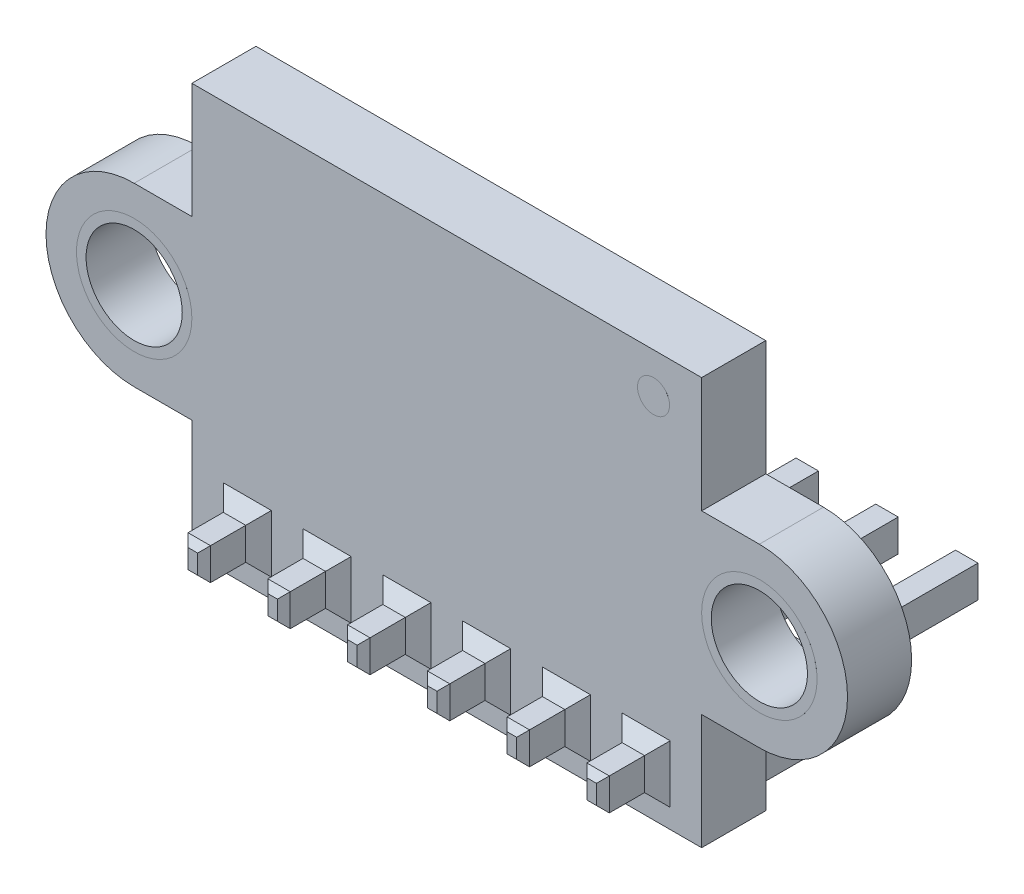
from build123d import *

# Parameters (mm, degrees)
SKETCH1_W                = 15.9
SKETCH1_H                = 12.7
BOSS_EXTRUDE1_DEPTH      = 1
SKETCH2_R                = 1.5
BOSS_EXTRUDE2_DEPTH      = 1
SKETCH3_W                = 15.6
SKETCH3_H                = 2.7
BOSS_EXTRUDE3_DEPTH      = 2.3
CHAMFER1_SIZE            = 0.5
SKETCH4_W                = 0.7
SKETCH4_H                = 1
BOSS_EXTRUDE4_DEPTH      = 5.9
BOSS_EXTRUDE4_DEPTH_BACK = 6
CHAMFER2_SIZE            = 0.2
CHAMFER3_SIZE            = 0.4
SKETCH5_R                = 1.8
SKETCH5_R_2              = 1.5
SKETCH5_R_3              = 0.5
BOSS_EXTRUDE5_DEPTH      = 0.0001


with BuildPart() as part:
    # Sketch1 → Boss-Extrude1 (new body, symmetric)
    with BuildSketch(Plane.XY):
        Rectangle(SKETCH1_W, SKETCH1_H)
    extrude(amount=BOSS_EXTRUDE1_DEPTH, both=True)

    # Sketch2 → Boss-Extrude2 (add, symmetric)
    with BuildSketch(Plane.XY):
        with BuildLine():
            Line((-9.75, 2.75), (-7.95, 2.75))
            Line((-7.95, 2.75), (-7.95, -2.75))
            Line((-7.95, -2.75), (-9.75, -2.75))
            ThreePointArc((-9.75, -2.75), (-12.5, 0), (-9.75, 2.75))
        make_face()
        with Locations((-9.75, 0)):
            Circle(SKETCH2_R, mode=Mode.SUBTRACT)
        with BuildLine():
            Line((9.75, -2.75), (7.95, -2.75))
            Line((7.95, -2.75), (7.95, 2.75))
            Line((7.95, 2.75), (9.75, 2.75))
            ThreePointArc((9.75, 2.75), (12.5, 0), (9.75, -2.75))
        make_face()
        with Locations((9.75, 0)):
            Circle(SKETCH2_R, mode=Mode.SUBTRACT)
    extrude(amount=BOSS_EXTRUDE2_DEPTH, both=True)

    # Sketch3 → Boss-Extrude3 (add)
    with BuildSketch(Plane(origin=(0, 0, -1), x_dir=(-1, 0, 0), z_dir=(0, 0, -1))):
        with Locations((0, -4.85)):
            Rectangle(SKETCH3_W, SKETCH3_H)
    extrude(amount=BOSS_EXTRUDE3_DEPTH)

    # Chamfer1
    chamfer1_edges = [part.edges().sort_by_distance(p)[0] for p in [
        (7.8, -3.5, -2.15),
        (7.8, -6.2, -2.15),
        (-7.8, -6.2, -2.15),
        (-7.8, -3.5, -2.15),
    ]]
    chamfer(chamfer1_edges, length=CHAMFER1_SIZE)

    # Sketch4 → Boss-Extrude4 (add, two sides)
    with BuildSketch(Plane(origin=(0, 0, -3.3), x_dir=(-1, 0, 0), z_dir=(0, 0, -1))) as boss_extrude4_sk:
        with Locations((-3.732, -4.85)):
            Rectangle(SKETCH4_W, SKETCH4_H)
        with Locations((-6.22, -4.85)):
            Rectangle(SKETCH4_W, SKETCH4_H)
        with Locations((-1.244, -4.85)):
            Rectangle(SKETCH4_W, SKETCH4_H)
        with Locations((1.244, -4.85)):
            Rectangle(SKETCH4_W, SKETCH4_H)
        with Locations((3.732, -4.85)):
            Rectangle(SKETCH4_W, SKETCH4_H)
        with Locations((6.22, -4.85)):
            Rectangle(SKETCH4_W, SKETCH4_H)
    extrude(amount=BOSS_EXTRUDE4_DEPTH)
    extrude(boss_extrude4_sk.sketch, amount=-BOSS_EXTRUDE4_DEPTH_BACK)

    # Chamfer2
    chamfer2_edges = [part.edges().sort_by_distance(p)[0] for p in [
        (4.082, -4.85, 2.7),
        (3.732, -4.35, 2.7),
        (3.382, -4.85, 2.7),
        (3.732, -5.35, 2.7),
        (4.082, -4.85, -9.2),
        (3.732, -5.35, -9.2),
        (3.382, -4.85, -9.2),
        (3.732, -4.35, -9.2),
        (1.594, -4.85, 2.7),
        (1.244, -4.35, 2.7),
        (0.894, -4.85, 2.7),
        (1.244, -5.35, 2.7),
        (1.594, -4.85, -9.2),
        (1.244, -5.35, -9.2),
        (0.894, -4.85, -9.2),
        (1.244, -4.35, -9.2),
        (-0.894, -4.85, 2.7),
        (-1.244, -4.35, 2.7),
        (-1.594, -4.85, 2.7),
        (-1.244, -5.35, 2.7),
        (-0.894, -4.85, -9.2),
        (-1.244, -5.35, -9.2),
        (-1.594, -4.85, -9.2),
        (-1.244, -4.35, -9.2),
        (-3.382, -4.85, 2.7),
        (-3.732, -4.35, 2.7),
        (-4.082, -4.85, 2.7),
        (-3.732, -5.35, 2.7),
        (-3.382, -4.85, -9.2),
        (-3.732, -5.35, -9.2),
        (-4.082, -4.85, -9.2),
        (-3.732, -4.35, -9.2),
        (-5.87, -4.85, 2.7),
        (-6.22, -4.35, 2.7),
        (-6.57, -4.85, 2.7),
        (-6.22, -5.35, 2.7),
        (-5.87, -4.85, -9.2),
        (-6.22, -5.35, -9.2),
        (-6.57, -4.85, -9.2),
        (-6.22, -4.35, -9.2),
        (6.57, -4.85, 2.7),
        (6.22, -4.35, 2.7),
        (5.87, -4.85, 2.7),
        (6.22, -5.35, 2.7),
        (6.57, -4.85, -9.2),
        (6.22, -5.35, -9.2),
        (5.87, -4.85, -9.2),
        (6.22, -4.35, -9.2),
    ]]
    chamfer(chamfer2_edges, length=CHAMFER2_SIZE)

    # Chamfer3
    chamfer3_edges = [part.edges().sort_by_distance(p)[0] for p in [
        (4.082, -4.85, 1),
        (3.732, -4.35, 1),
        (3.382, -4.85, 1),
        (3.732, -5.35, 1),
        (1.594, -4.85, 1),
        (1.244, -4.35, 1),
        (0.894, -4.85, 1),
        (1.244, -5.35, 1),
        (-0.894, -4.85, 1),
        (-1.244, -4.35, 1),
        (-1.594, -4.85, 1),
        (-1.244, -5.35, 1),
        (-3.382, -4.85, 1),
        (-3.732, -4.35, 1),
        (-4.082, -4.85, 1),
        (-3.732, -5.35, 1),
        (-5.87, -4.85, 1),
        (-6.22, -4.35, 1),
        (-6.57, -4.85, 1),
        (-6.22, -5.35, 1),
        (6.57, -4.85, 1),
        (6.22, -4.35, 1),
        (5.87, -4.85, 1),
        (6.22, -5.35, 1),
    ]]
    chamfer(chamfer3_edges, length=CHAMFER3_SIZE)

    # Sketch5 → Boss-Extrude5 (add)
    with BuildSketch(Plane.XY.offset(1)):
        with Locations((-9.75, 0)):
            Circle(SKETCH5_R)
        with Locations((-9.75, 0)):
            Circle(SKETCH5_R_2, mode=Mode.SUBTRACT)
        with Locations((9.75, 0)):
            Circle(SKETCH5_R)
        with Locations((9.75, 0)):
            Circle(SKETCH5_R_2, mode=Mode.SUBTRACT)
        with Locations((6.45, 5.1)):
            Circle(SKETCH5_R_3)
    extrude(amount=BOSS_EXTRUDE5_DEPTH)


solid = part.part
